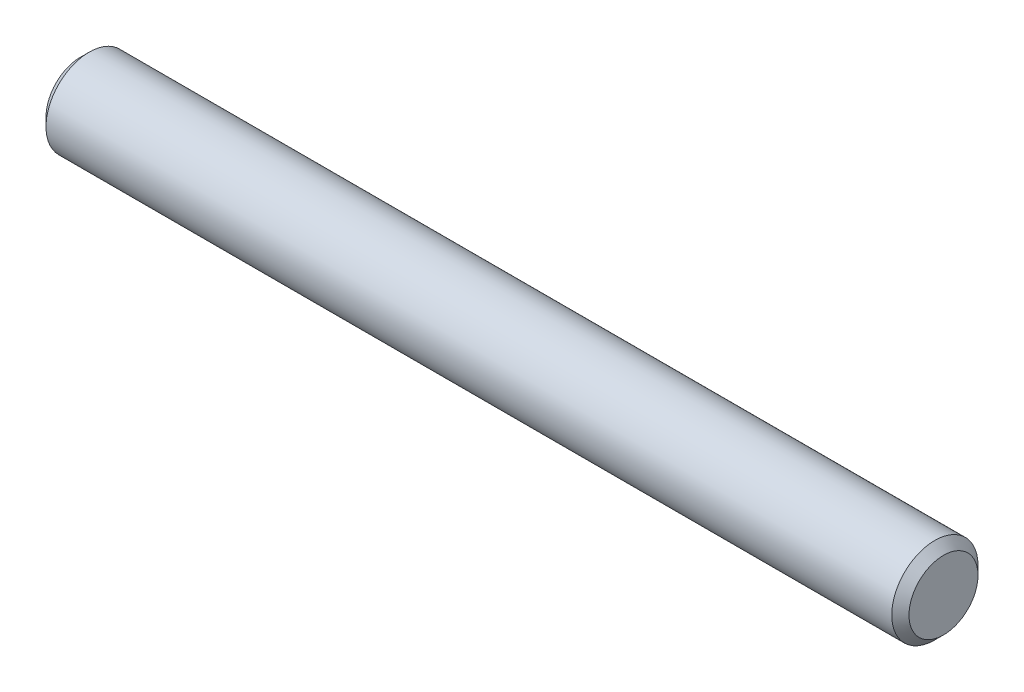
from build123d import *

# Parameters (mm, degrees)
SKETCH2_R           = 0.79375
EXTRUDE1_DEPTH      = 7.9375
EXTRUDE1_DEPTH_BACK = 7.9375
CHAMFER1_SIZE       = 0.15875


with BuildPart() as part:
    # Sketch2 → Extrude1 (new body, two sides)
    with BuildSketch(Plane(origin=(0, 0, 0), x_dir=(0, 0, -1), z_dir=(1, 0, 0))) as extrude1_sk:
        Circle(SKETCH2_R)
    extrude(amount=EXTRUDE1_DEPTH)
    extrude(extrude1_sk.sketch, amount=-EXTRUDE1_DEPTH_BACK)

    # Chamfer1
    chamfer1_edges = [part.edges().sort_by_distance(p)[0] for p in [
        (-7.9375, 0, 0.79375),
        (7.9375, 0, 0.79375),
    ]]
    chamfer(chamfer1_edges, length=CHAMFER1_SIZE)


solid = part.part
